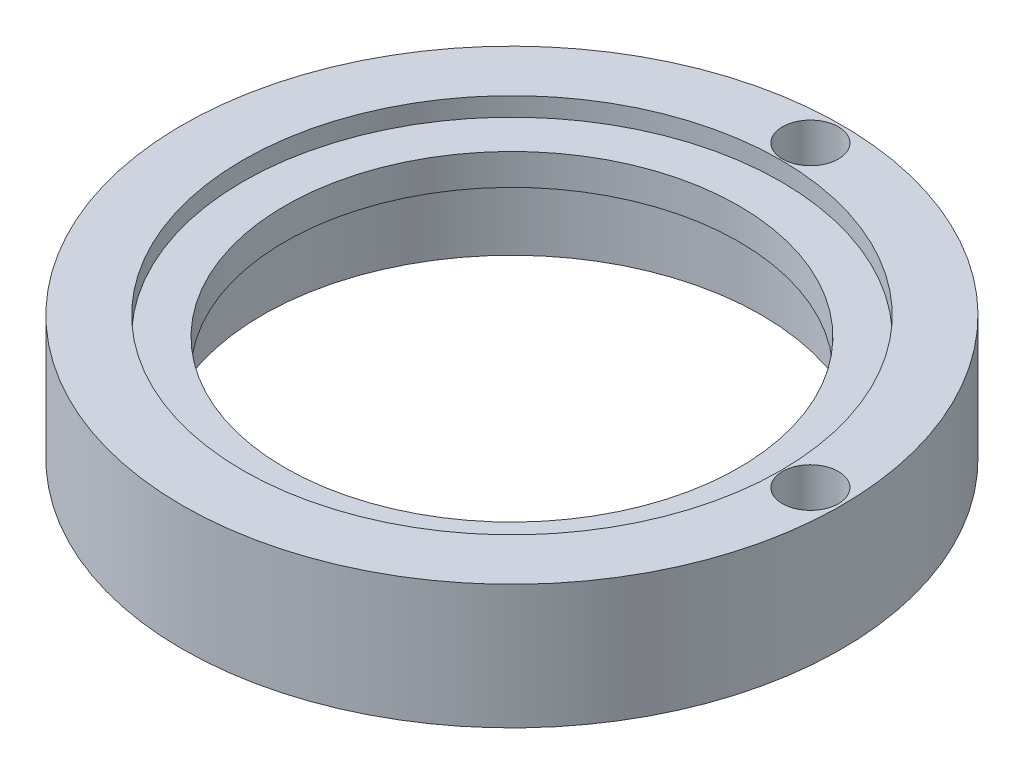
from build123d import *

# Parameters (mm, degrees)
SKETCH1_R           = 53
SKETCH1_R_2         = 36.5
BOSS_EXTRUDE1_DEPTH = 20
SKETCH2_R           = 43.25
LED_RING_DEPTH      = 3
SKETCH3_R           = 40.1
SPINDLE_DEPTH       = 12
SKETCH4_R           = 4.5
LASERS_DEPTH        = 21


with BuildPart() as part:
    # Sketch1 → Boss-Extrude1 (new body)
    with BuildSketch(Plane(origin=(0, 0, 0), x_dir=(1, 0, 0), z_dir=(0, 1, 0))):
        Circle(SKETCH1_R)
        Circle(SKETCH1_R_2, mode=Mode.SUBTRACT)
    extrude(amount=BOSS_EXTRUDE1_DEPTH)

    # Sketch2 → LED-ring (cut)
    with BuildSketch(Plane(origin=(0, 20, 0), x_dir=(1, 0, 0), z_dir=(0, 1, 0))):
        Circle(SKETCH2_R)
    extrude(amount=-LED_RING_DEPTH, mode=Mode.SUBTRACT)

    # Sketch3 → spindle (cut)
    with BuildSketch(Plane.XZ):
        Circle(SKETCH3_R)
    extrude(amount=-SPINDLE_DEPTH, mode=Mode.SUBTRACT)

    # Sketch4 → lasers (cut, through all)
    with BuildSketch(Plane(origin=(0, 20, 0), x_dir=(1, 0, 0), z_dir=(0, 1, 0))):
        with Locations((0, 48)):
            Circle(SKETCH4_R)
        with Locations((48, 0)):
            Circle(SKETCH4_R)
    extrude(amount=-LASERS_DEPTH, mode=Mode.SUBTRACT)


solid = part.part
